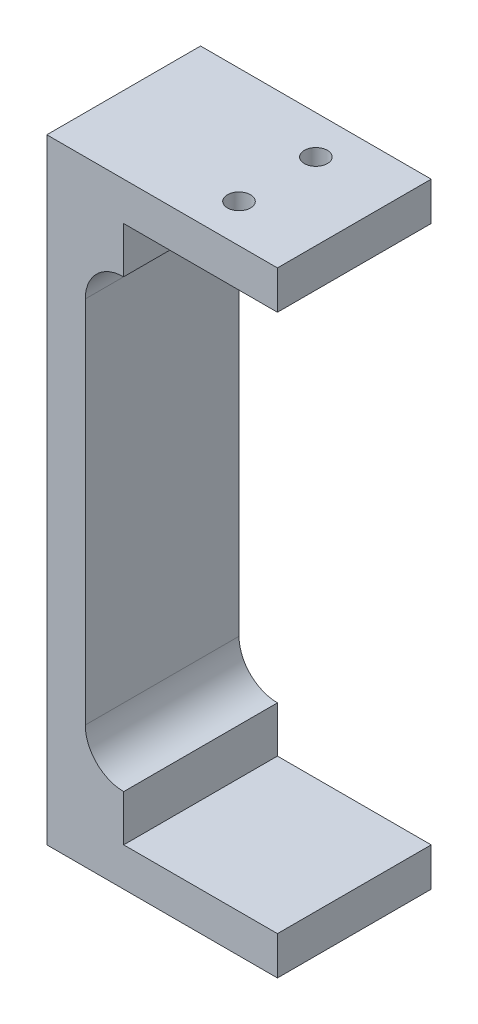
from build123d import *

# Parameters (mm, degrees)
BOSS_EXTRUDE1_DEPTH = 20
BOSS_EXTRUDE2_DEPTH = 20
SKETCH4_R           = 1.5
CUT_EXTRUDE1_DEPTH  = 5


with BuildPart() as part:
    # Sketch1 → Boss-Extrude1 (new body)
    with BuildSketch(Plane.XY):
        Polygon((20, 0), (-10, 0), (-10, -80), (20, -80), (20, -75), (-5, -75), (-5, -5), (20, -5), align=None)
    extrude(amount=BOSS_EXTRUDE1_DEPTH)

    # Sketch3 → Boss-Extrude2 (add)
    with BuildSketch(Plane.XY):
        with BuildLine():
            Line((0, -5), (-5, -5))
            Line((-5, -5), (-5, -16))
            ThreePointArc((-5, -16), (-3.535533906, -12.464466094), (0, -11))
            Line((0, -11), (0, -5))
        make_face()
        with BuildLine():
            Line((-5, -75), (0, -75))
            Line((0, -75), (0, -69))
            ThreePointArc((0, -69), (-3.535533906, -67.535533906), (-5, -64))
            Line((-5, -64), (-5, -75))
        make_face()
    extrude(amount=BOSS_EXTRUDE2_DEPTH)

    # Sketch4 → Cut-Extrude1 (cut)
    with BuildSketch(Plane(origin=(0, 0, 0), x_dir=(1, 0, 0), z_dir=(0, 1, 0))):
        with Locations((10, -5)):
            Circle(SKETCH4_R)
        with Locations((10, -15)):
            Circle(SKETCH4_R)
    extrude(amount=-CUT_EXTRUDE1_DEPTH, mode=Mode.SUBTRACT)


solid = part.part
